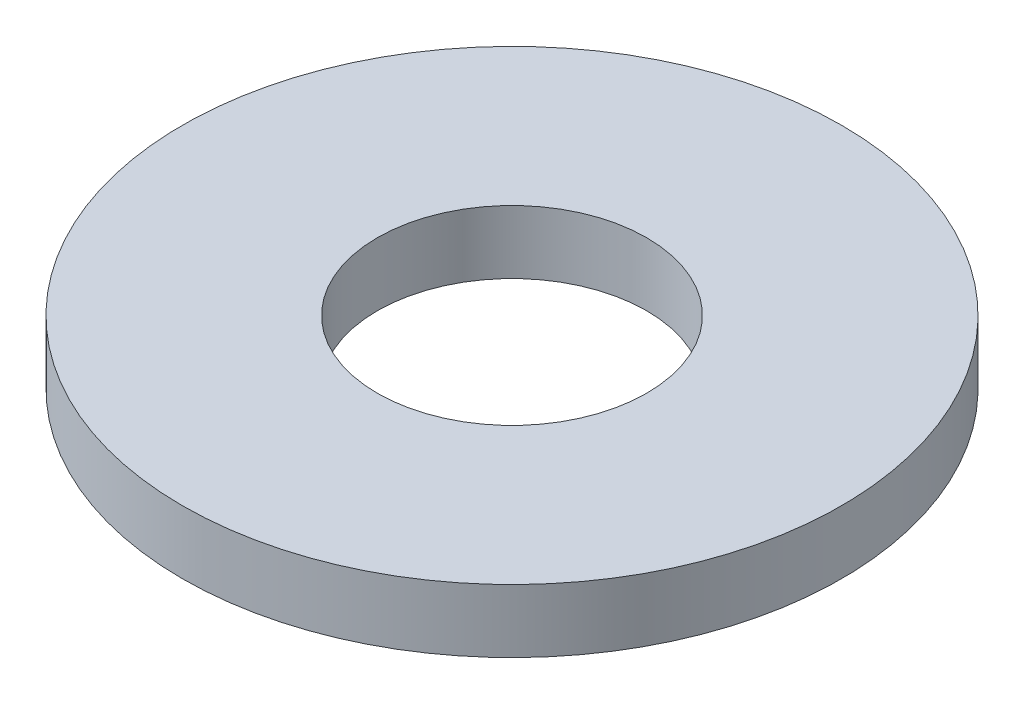
from build123d import *

# Parameters (mm, degrees)
SKETCH1_R           = 17.4625
BOSS_EXTRUDE1_DEPTH = 3.3528
SKETCH5_R           = 7.1374
CUT_EXTRUDE1_DEPTH  = 4.3528


with BuildPart() as part:
    # Sketch1 → Boss-Extrude1 (new body)
    with BuildSketch(Plane(origin=(0, 0, 0), x_dir=(1, 0, 0), z_dir=(0, 1, 0))):
        with Locations(Location((0, 0, 0), (0, 0, 270))):  # turned: the seam where the file's is
            Circle(SKETCH1_R)
    extrude(amount=BOSS_EXTRUDE1_DEPTH)

    # Sketch5 → Cut-Extrude1 (cut, through all)
    with BuildSketch(Plane(origin=(0, 3.3528, 0), x_dir=(-1, 0, 0), z_dir=(0, 1, 0))):
        with Locations(Location((0, 0, 0), (0, 0, 90))):  # turned: the seam where the file's is
            Circle(SKETCH5_R)
    extrude(amount=-CUT_EXTRUDE1_DEPTH, mode=Mode.SUBTRACT)


solid = part.part
